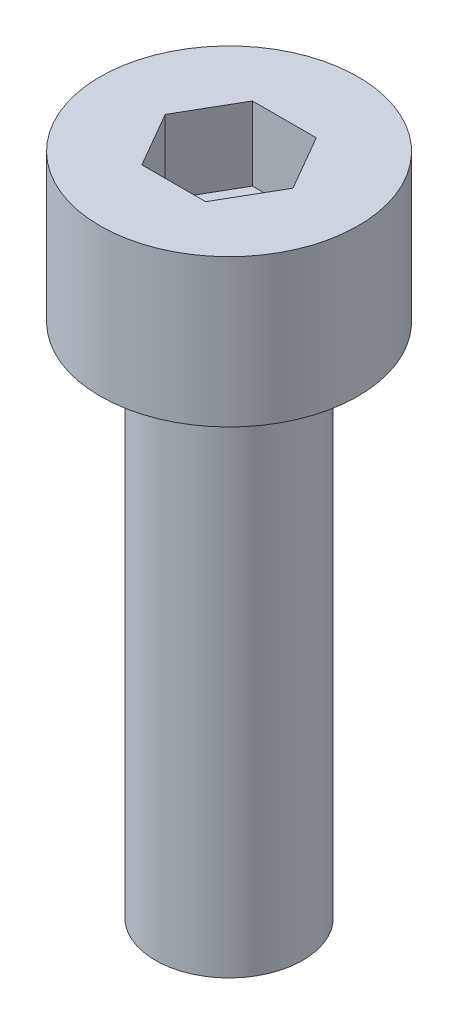
from build123d import *

# Parameters (mm, degrees)
SKETCH_1_R            = 3.5
EXTRUDE_249_DEPTH     = 4
CUT_EXTRUDE_379_DEPTH = 2
SKETCH_3_R            = 2
EXTRUDE_480_DEPTH     = 14


with BuildPart() as part:
    # 草图1 → Extrude 249 (new body)
    with BuildSketch(Plane(origin=(0, 0, 0), x_dir=(1, 0, 0), z_dir=(0, 1, 0))):
        Circle(SKETCH_1_R)
    extrude(amount=EXTRUDE_249_DEPTH)

    # 草图2 → Cut-Extrude 379 (cut)
    with BuildSketch(Plane(origin=(0, 4, 0), x_dir=(1, 0, 0), z_dir=(0, 1, 0))):
        Polygon((1.732050808, 0), (0.866025404, 1.5), (-0.866025404, 1.5), (-1.732050808, 0), (-0.866025404, -1.5), (0.866025404, -1.5), align=None)
    extrude(amount=-CUT_EXTRUDE_379_DEPTH, mode=Mode.SUBTRACT)

    # 草图3 → Extrude 480 (add)
    with BuildSketch(Plane.XZ):
        Circle(SKETCH_3_R)
    extrude(amount=EXTRUDE_480_DEPTH)


solid = part.part
